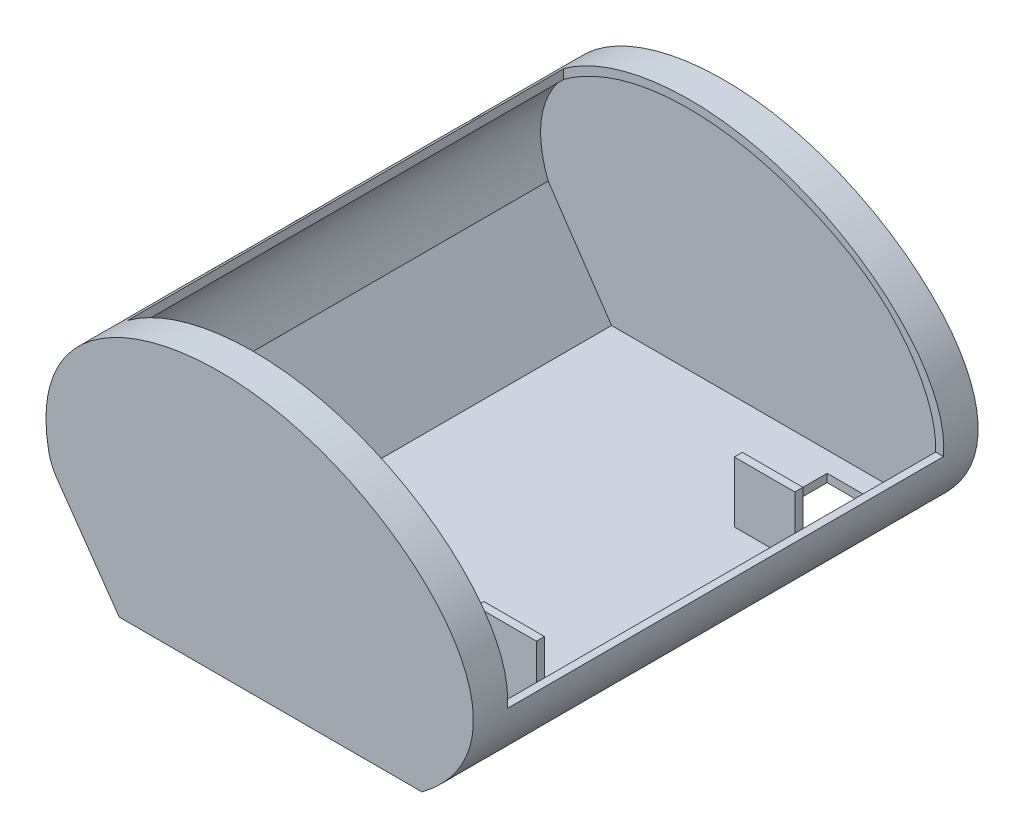
from build123d import *

# Parameters (mm, degrees)
BOSS_EXTRUDE1_DEPTH     = 250
CUT_EXTRUDE1_START      = -7
CUT_EXTRUDE1_DEPTH      = 236
CUT_EXTRUDE2_START      = 40
SKETCH3_W               = 188.244995532
SKETCH3_H               = 216
CUT_EXTRUDE2_DEPTH      = 236
FILLET1_R               = 25
SKETCH6_W               = 30
SKETCH6_H               = 4
BOSS_EXTRUDE2_DEPTH     = 30
SKETCH7_W               = 30
SKETCH7_H               = 42
CUT_EXTRUDE3_DEPTH      = 127.205636965
CUT_EXTRUDE3_DEPTH_BACK = 5.0000001
SKETCH8_W               = 30
SKETCH8_H               = 4
BOSS_EXTRUDE3_DEPTH     = 30
SKETCH9_W               = 30
SKETCH9_H               = 42
CUT_EXTRUDE4_DEPTH      = 127.205636965
CUT_EXTRUDE4_DEPTH_BACK = 5.0000001


with BuildPart() as part:
    # Sketch1 → Boss-Extrude1 (new body)
    with BuildSketch(Plane.XY):
        with BuildLine():
            Line((-74.466852712, 0), (75.533147288, 0))
            add(Edge.make_bspline(
                [(75.533147288, 0), (138.063372934, 47.200510513), (16.470001542, 172.007803308), (-124.949591118, 111.301552399), (-108.081203548, 48.03596108)],
                knots=[0, 0, 0, 0, 0.526874503, 1, 1, 1, 1], degree=3))
            Line((-108.081203548, 48.03596108), (-74.466852712, 0))
        make_face()
    extrude(amount=BOSS_EXTRUDE1_DEPTH)

    # Sketch2 → Cut-Extrude1 (cut)
    with BuildSketch(Plane.XY.offset(250).offset(CUT_EXTRUDE1_START)):
        with BuildLine():
            Line((-105.002588912, 50.278247003), (-73.603513663, 4))
            Line((-73.603513663, 4), (73.163375947, 4))
            Line((73.163375947, 4), (80.793344513, 10.72835486))
            add(Edge.make_bspline(
                [(80.793344513, 10.72835486), (92.651817418, 19.563808902), (103.009839439, 45.205558115), (79.954027593, 88.91810325), (40.607899873, 112.95610518), (-11.204752472, 129.142722192), (-79.431682825, 124.667635826), (-117.344714605, 82.323825457), (-105.002588912, 50.278247003)],
                knots=[0.016278873, 0.016278873, 0.016278873, 0.016278873, 0.12675304, 0.268313114, 0.414746674, 0.542882576, 0.761532881, 1, 1, 1, 1], degree=3))
        make_face()
    extrude(amount=-CUT_EXTRUDE1_DEPTH, mode=Mode.SUBTRACT)

    # Sketch3 → Cut-Extrude2 (cut)
    with BuildSketch(Plane(origin=(0, 0, 0), x_dir=(1, 0, 0), z_dir=(0, 1, 0)).offset(CUT_EXTRUDE2_START)):
        with Locations((6.82953452, -125)):
            Rectangle(SKETCH3_W, SKETCH3_H)
    extrude(amount=CUT_EXTRUDE2_DEPTH, mode=Mode.SUBTRACT)

    # Fillet1
    fillet1_edges = [part.edges().sort_by_distance(p)[0] for p in [
        (-108.081203548, 48.03596108, 125),
    ]]
    fillet(fillet1_edges, radius=FILLET1_R)

    # Sketch6 → Boss-Extrude2 (add)
    with BuildSketch(Plane(origin=(0, 4, 0), x_dir=(1, 0, 0), z_dir=(0, 1, 0))):
        with Locations((58.163375947, -189)):
            Rectangle(SKETCH6_W, SKETCH6_H)
    extrude(amount=BOSS_EXTRUDE2_DEPTH)

    # Sketch7 → Cut-Extrude3 (cut, two sides)
    with BuildSketch(Plane(origin=(0, 4, 0), x_dir=(1, 0, 0), z_dir=(0, 1, 0))) as cut_extrude3_sk:
        with Locations((58.163375947, -212)):
            Rectangle(SKETCH7_W, SKETCH7_H)
    extrude(amount=CUT_EXTRUDE3_DEPTH, mode=Mode.SUBTRACT)
    extrude(cut_extrude3_sk.sketch, amount=-CUT_EXTRUDE3_DEPTH_BACK, mode=Mode.SUBTRACT)

    # Sketch8 → Boss-Extrude3 (add)
    with BuildSketch(Plane(origin=(0, 4, 0), x_dir=(1, 0, 0), z_dir=(0, 1, 0))):
        with Locations((58.163375947, -61)):
            Rectangle(SKETCH8_W, SKETCH8_H)
    extrude(amount=BOSS_EXTRUDE3_DEPTH)

    # Sketch9 → Cut-Extrude4 (cut, two sides)
    with BuildSketch(Plane(origin=(0, 4, 0), x_dir=(1, 0, 0), z_dir=(0, 1, 0))) as cut_extrude4_sk:
        with Locations((58.163375947, -38)):
            Rectangle(SKETCH9_W, SKETCH9_H)
    extrude(amount=CUT_EXTRUDE4_DEPTH, mode=Mode.SUBTRACT)
    extrude(cut_extrude4_sk.sketch, amount=-CUT_EXTRUDE4_DEPTH_BACK, mode=Mode.SUBTRACT)


solid = part.part
